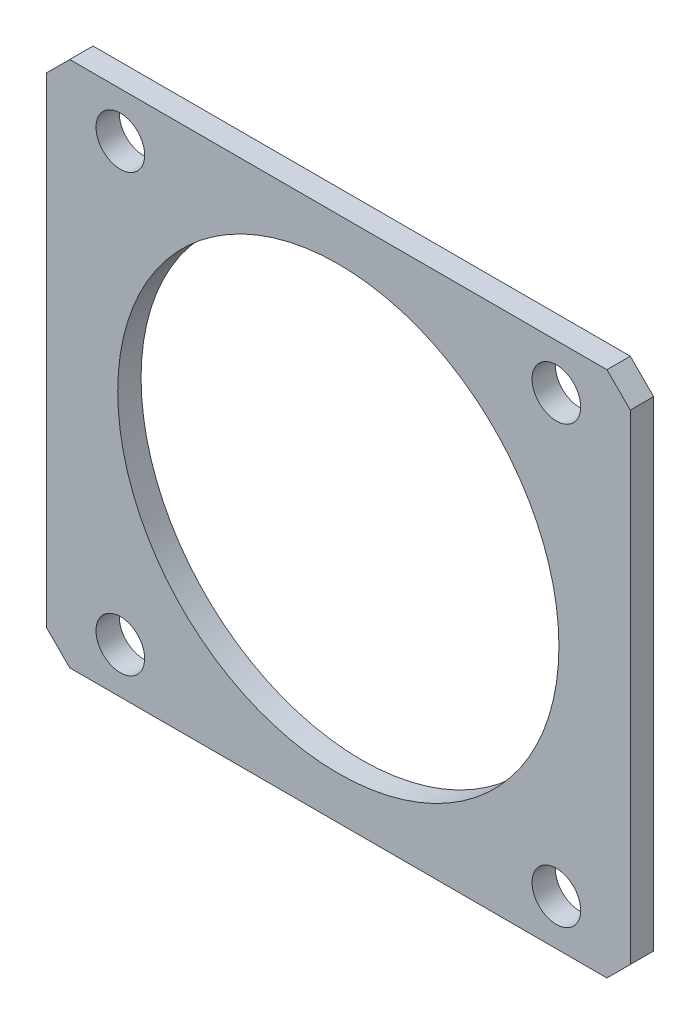
from build123d import *

# Parameters (mm, degrees)
SKETCH1_W                      = 57.15
SKETCH1_H                      = 51.562
SKETCH1_R                      = 21.59
BOSS_EXTRUDE1_DEPTH            = 2.286
F_3_16_0_1875_DIAMETER_HOLE1_D = 4.7625
CHAMFER1_SIZE                  = 2.286


with BuildPart() as part:
    # Sketch1 → Boss-Extrude1 (new body)
    with BuildSketch(Plane.XY):
        Rectangle(SKETCH1_W, SKETCH1_H)
        Circle(SKETCH1_R, mode=Mode.SUBTRACT)
    extrude(amount=BOSS_EXTRUDE1_DEPTH)

    # 3/16 (0.1875) Diameter Hole1 (through all)
    with Locations(Plane.XY.offset(2.286)):
        with Locations((21.336, 21.336), (-21.336, 21.336), (-21.336, -21.336), (21.336, -21.336)):
            Hole(F_3_16_0_1875_DIAMETER_HOLE1_D / 2)

    # Chamfer1
    chamfer1_edges = [part.edges().sort_by_distance(p)[0] for p in [
        (-28.575, 25.781, 1.143),
        (28.575, 25.781, 1.143),
        (28.575, -25.781, 1.143),
        (-28.575, -25.781, 1.143),
    ]]
    chamfer(chamfer1_edges, length=CHAMFER1_SIZE)


solid = part.part
